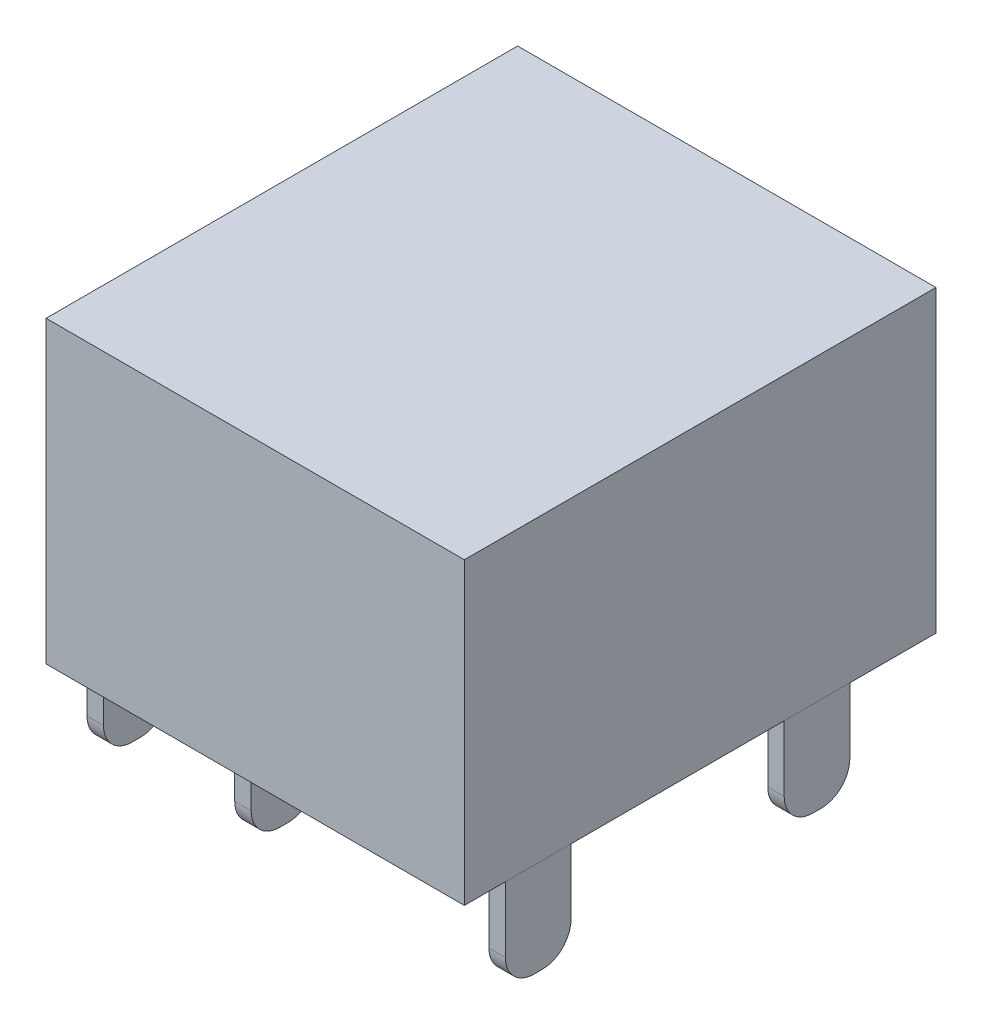
from build123d import *

# Parameters (mm, degrees)
SKETCH_1_W          = 11.5
SKETCH_1_H          = 7.3
EXTRUDE_1_DEPTH     = 10.2
SKETCH_2_R          = 3
SKETCH_2_R_2        = 1.25
CUT_EXTRUDE_1_DEPTH = 8.3
FILLET_1_R          = 1.12
SKETCH_3_W          = 0.4
SKETCH_3_H          = 1.6
EXTRUDE_2_DEPTH     = 2.3
EXTRUDE_2_2_DEPTH   = 2.3
EXTRUDE_2_3_DEPTH   = 2.3
EXTRUDE_2_4_DEPTH   = 2.3
EXTRUDE_2_5_DEPTH   = 2.3
FILLET_2_R          = 0.7
FILLET_3_R          = 0.7
FILLET_4_R          = 0.7
FILLET_5_R          = 0.7
FILLET_6_R          = 0.7
SKETCH_4_W          = 1.7
SKETCH_4_H          = 1.7
EXTRUDE_3_DEPTH     = 1.2
FILLET_7_R          = 0.2
FILLET_8_R          = 0.2


with BuildPart() as part:
    # Эскиз1 → Бобышка-Вытянуть1 (new body)
    with BuildSketch(Plane(origin=(0, 0, 0), x_dir=(0, 0, -1), z_dir=(1, 0, 0))):
        with Locations((5.75, 3.65)):
            Rectangle(SKETCH_1_W, SKETCH_1_H)
    extrude(amount=EXTRUDE_1_DEPTH)

    # Эскиз2 → Вырез-Вытянуть1 (cut)
    with BuildSketch(Plane(origin=(0, 0, -11.5), x_dir=(-1, 0, 0), z_dir=(0, 0, -1))):
        with Locations((-4, 3.65)):
            Circle(SKETCH_2_R)
        with Locations((-4, 3.65)):
            Circle(SKETCH_2_R_2, mode=Mode.SUBTRACT)
    extrude(amount=-CUT_EXTRUDE_1_DEPTH, mode=Mode.SUBTRACT)

    # Скругление1
    fillet_1_edges = [part.edges().sort_by_distance(p)[0] for p in [
        (5.25, 3.65, -11.5),
    ]]
    fillet(fillet_1_edges, radius=FILLET_1_R)

    # Эскиз4 → Бобышка-Вытянуть3 (add)
    with BuildSketch(Plane.XZ):
        with Locations((3.85, -7.35)):
            Rectangle(SKETCH_4_W, SKETCH_4_H)
    extrude(amount=EXTRUDE_3_DEPTH)

    # Скругление7
    fillet_7_edges = [part.edges().sort_by_distance(p)[0] for p in [
        (3, -0.6, -6.5),
        (3, -0.6, -8.2),
        (4.7, -0.6, -8.2),
        (4.7, -0.6, -6.5),
    ]]
    fillet(fillet_7_edges, radius=FILLET_7_R)

    # Скругление8
    fillet_8_edges = [part.edges().sort_by_distance(p)[0] for p in [
        (7, 3.65, -11.5),
    ]]
    fillet(fillet_8_edges, radius=FILLET_8_R)


with BuildPart() as body_2:
    # Эскиз3 → Бобышка-Вытянуть2 (new body)
    with BuildSketch(Plane.XZ):
        with Locations((0.2, -1.8)):
            Rectangle(SKETCH_3_W, SKETCH_3_H)
    extrude(amount=EXTRUDE_2_DEPTH)

    # Скругление2
    fillet_2_edges = [body_2.edges().sort_by_distance(p)[0] for p in [
        (0.2, -2.3, -1),
        (0.2, -2.3, -2.6),
    ]]
    fillet(fillet_2_edges, radius=FILLET_2_R)


with BuildPart() as body_3:
    # Эскиз3 → Extrude 2 2 (new body)
    with BuildSketch(Plane.XZ):
        with Locations((0.2, -8.6)):
            Rectangle(SKETCH_3_W, SKETCH_3_H)
    extrude(amount=EXTRUDE_2_2_DEPTH)

    # Скругление5
    fillet_5_edges = [body_3.edges().sort_by_distance(p)[0] for p in [
        (0.2, -2.3, -7.8),
        (0.2, -2.3, -9.4),
    ]]
    fillet(fillet_5_edges, radius=FILLET_5_R)


with BuildPart() as body_4:
    # Эскиз3 → Extrude 2 3 (new body)
    with BuildSketch(Plane.XZ):
        with Locations((10, -8.6)):
            Rectangle(SKETCH_3_W, SKETCH_3_H)
    extrude(amount=EXTRUDE_2_3_DEPTH)

    # Скругление6
    fillet_6_edges = [body_4.edges().sort_by_distance(p)[0] for p in [
        (10, -2.3, -7.8),
        (10, -2.3, -9.4),
    ]]
    fillet(fillet_6_edges, radius=FILLET_6_R)


with BuildPart() as body_5:
    # Эскиз3 → Extrude 2 4 (new body)
    with BuildSketch(Plane.XZ):
        with Locations((10, -1.8)):
            Rectangle(SKETCH_3_W, SKETCH_3_H)
    extrude(amount=EXTRUDE_2_4_DEPTH)

    # Скругление4
    fillet_4_edges = [body_5.edges().sort_by_distance(p)[0] for p in [
        (10, -2.3, -1),
        (10, -2.3, -2.6),
    ]]
    fillet(fillet_4_edges, radius=FILLET_4_R)


with BuildPart() as body_6:
    # Эскиз3 → Extrude 2 5 (new body)
    with BuildSketch(Plane.XZ):
        with Locations((3.8, -1.8)):
            Rectangle(SKETCH_3_W, SKETCH_3_H)
    extrude(amount=EXTRUDE_2_5_DEPTH)

    # Скругление3
    fillet_3_edges = [body_6.edges().sort_by_distance(p)[0] for p in [
        (3.8, -2.3, -1),
        (3.8, -2.3, -2.6),
    ]]
    fillet(fillet_3_edges, radius=FILLET_3_R)


solid = Compound([part.part, body_2.part, body_3.part, body_4.part, body_5.part, body_6.part])
